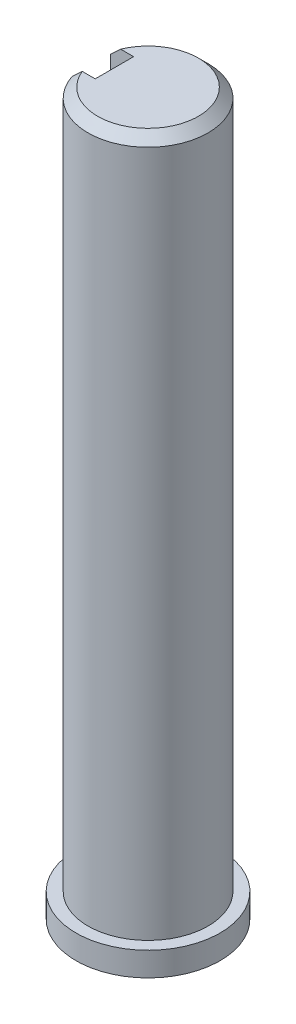
from build123d import *

# Parameters (mm, degrees)
ESBO_O3_W             = 8
ESBO_O3_H             = 8
CORTE_EXTRUS_O1_DEPTH = 20
CHANFRO1_SIZE         = 2


with BuildPart() as part:
    # Sketch1 → Revolve1 (revolve)
    with BuildSketch(Plane.XY):
        Polygon((0, 150), (12.5, 150), (12.5, 5), (15, 5), (15, 0), (0, 0), align=None)
    revolve(axis=Axis((0, 0, 0), (0, 1, 0)))

    # Esboço3 → Corte-extrusão1 (cut)
    with BuildSketch(Plane(origin=(0, 150, 0), x_dir=(1, 0, 0), z_dir=(0, 1, 0))):
        with Locations((-11, 0)):
            Rectangle(ESBO_O3_W, ESBO_O3_H)
    extrude(amount=-CORTE_EXTRUS_O1_DEPTH, mode=Mode.SUBTRACT)

    # Chanfro1
    chanfro1_edges = [part.edges().sort_by_distance(p)[0] for p in [
        (2.026821276, 150, -12.33458534),
    ]]
    chamfer(chanfro1_edges, length=CHANFRO1_SIZE)


solid = part.part
